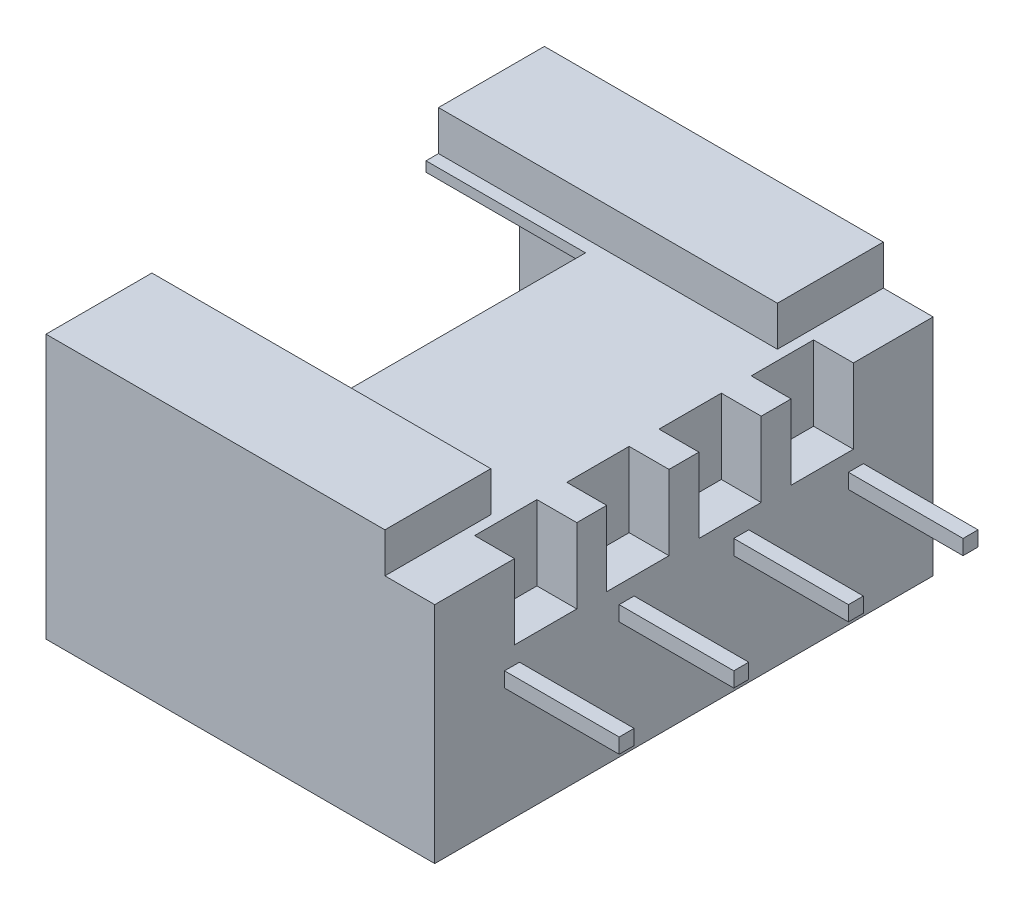
from build123d import *

# Parameters (mm, degrees)
ESQUISSE7_W                = 8
ESQUISSE7_H                = 0.3
BOSS_EXTRU_2_DEPTH         = 0.3
ESQUISSE12_W               = 7.8
ESQUISSE12_H               = 10
BOSS_EXTRU_3_DEPTH         = 5.3
ENL_V_MAT_EXTRU_3_DEPTH    = 6.1
ESQUISSE14_W               = 3.2
ESQUISSE14_H               = 5.25
ENL_V_MAT_EXTRU_4_DEPTH    = 1
R_P_TITION_LIN_AIRE1_COUNT = 4
R_P_TITION_LIN_AIRE1_PITCH = 2.3
ESQUISSE15_W               = 3.397317762
ESQUISSE15_H               = 5.75
ENL_V_MAT_EXTRU_5_DEPTH    = 0.8
ESQUISSE16_W               = 9.511143681
ESQUISSE16_H               = 5.75
ENL_V_MAT_EXTRU_6_DEPTH    = 0.8
ESQUISSE17_W               = 2.077305242
ESQUISSE17_H               = 10.679300776
ENL_V_MAT_EXTRU_7_DEPTH    = 0.8
ESQUISSE18_W               = 1.3
ESQUISSE18_H               = 1.25
ENL_V_MAT_EXTRU_8_DEPTH    = 1.5


with BuildPart() as part:
    # Esquisse7 → Boss.-Extru.2 (new body)
    with BuildSketch(Plane(origin=(0, 0, -3.6), x_dir=(-1, 0, 0), z_dir=(0, 0, -1))):
        with Locations((-7.55, 3.25)):
            Rectangle(ESQUISSE7_W, ESQUISSE7_H)
    boss_extru_2 = extrude(amount=-BOSS_EXTRU_2_DEPTH)


with BuildPart() as body_2:
    # Esquisse12 → Boss.-Extru.3 (new body)
    with BuildSketch(Plane(origin=(0, 6.05, 0), x_dir=(1, 0, 0), z_dir=(0, 1, 0))):
        with Locations((5.35, 0)):
            Rectangle(ESQUISSE12_W, ESQUISSE12_H)
    extrude(amount=-BOSS_EXTRU_3_DEPTH)

    # Esquisse13 → Enlèv. mat.-Extru.3 (cut)
    with BuildSketch(Plane.ZY.offset(-1.45)):
        Polygon((-4.5, 5.55), (-4.5, 1.25), (4.5, 1.25), (4.5, 5.55), (3.5, 5.55), (3.5, 5.05), (-3.5, 5.05), (-3.5, 5.55), align=None)
    extrude(amount=-ENL_V_MAT_EXTRU_3_DEPTH, mode=Mode.SUBTRACT)

    # Esquisse14 → Enlèv. mat.-Extru.4 (cut)
    with BuildSketch(Plane(origin=(0, 6.05, 0), x_dir=(-1, 0, 0), z_dir=(0, 1, 0))):
        with Locations((-3.05, 0)):
            Rectangle(ESQUISSE14_W, ESQUISSE14_H)
    extrude(amount=-ENL_V_MAT_EXTRU_4_DEPTH, mode=Mode.SUBTRACT)

    # Esquisse15 → Enlèv. mat.-Extru.5 (cut)
    with BuildSketch(Plane(origin=(0, 6.05, 0), x_dir=(1, 0, 0), z_dir=(0, 1, 0))):
        with Locations((2.951341119, 0)):
            Rectangle(ESQUISSE15_W, ESQUISSE15_H)
    extrude(amount=-ENL_V_MAT_EXTRU_5_DEPTH, mode=Mode.SUBTRACT)

    # Esquisse16 → Enlèv. mat.-Extru.6 (cut)
    with BuildSketch(Plane(origin=(0, 6.05, 0), x_dir=(1, 0, 0), z_dir=(0, 1, 0))):
        with Locations((6.205571841, 0)):
            Rectangle(ESQUISSE16_W, ESQUISSE16_H)
    extrude(amount=-ENL_V_MAT_EXTRU_6_DEPTH, mode=Mode.SUBTRACT)

    # Esquisse17 → Enlèv. mat.-Extru.7 (cut)
    with BuildSketch(Plane(origin=(0, 6.05, 0), x_dir=(1, 0, 0), z_dir=(0, 1, 0))):
        with Locations((9.288652621, 0.006970823)):
            Rectangle(ESQUISSE17_W, ESQUISSE17_H)
    extrude(amount=-ENL_V_MAT_EXTRU_7_DEPTH, mode=Mode.SUBTRACT)

    # Esquisse18 → Enlèv. mat.-Extru.8 (cut)
    with BuildSketch(Plane(origin=(0, 5.25, 0), x_dir=(1, 0, 0), z_dir=(0, 1, 0))):
        with Locations((9.1, 0.925)):
            Rectangle(ESQUISSE18_W, ESQUISSE18_H)
        with Locations((9.1, 2.775)):
            Rectangle(ESQUISSE18_W, ESQUISSE18_H)
        with Locations((9.1, -2.775)):
            Rectangle(ESQUISSE18_W, ESQUISSE18_H)
        with Locations((9.1, -0.925)):
            Rectangle(ESQUISSE18_W, ESQUISSE18_H)
    extrude(amount=-ENL_V_MAT_EXTRU_8_DEPTH, mode=Mode.SUBTRACT)


with BuildPart() as r_p_tition_lin_aire1_1:
    # Répétition linéaire1: Boss.-Extru.2 ×4
    with Locations(*[(0, 0, i * R_P_TITION_LIN_AIRE1_PITCH) for i in range(1, R_P_TITION_LIN_AIRE1_COUNT)]):
        add(boss_extru_2)


solid = Compound([part.part, body_2.part, r_p_tition_lin_aire1_1.part])
